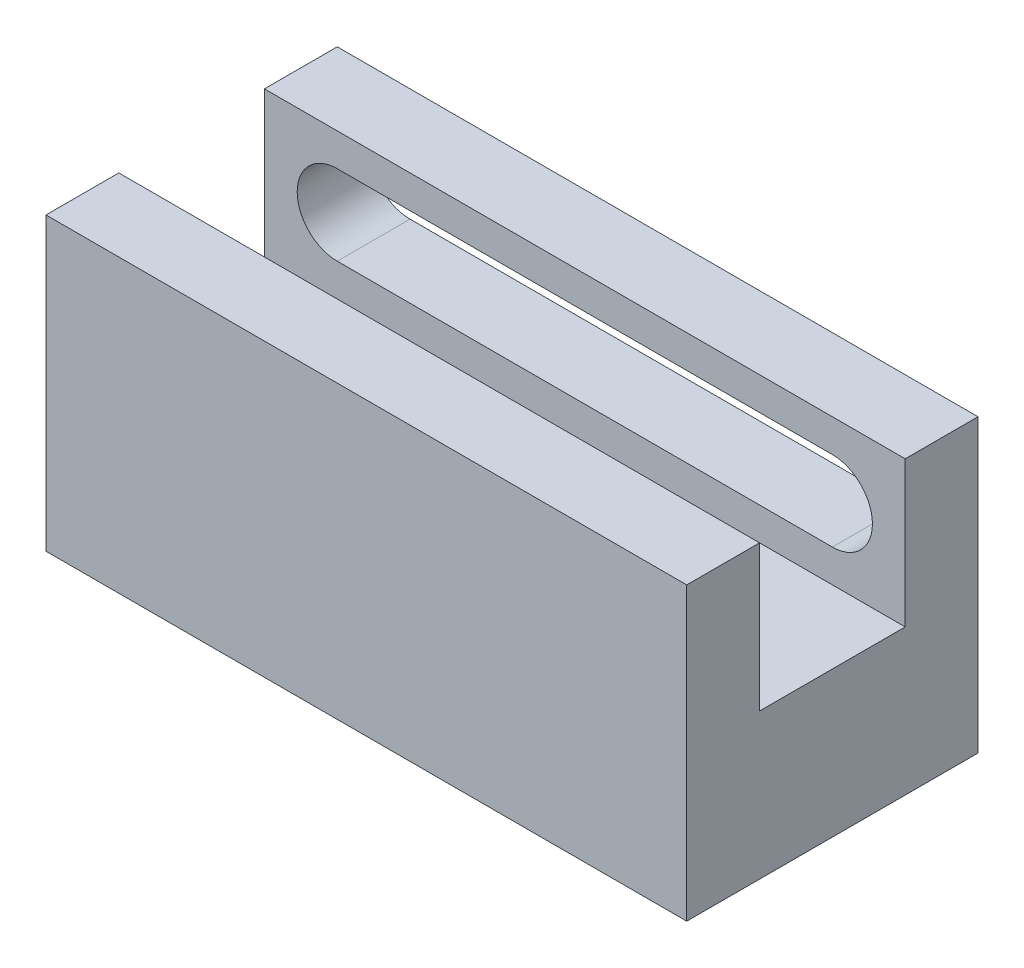
from build123d import *

# Parameters (mm, degrees)
SKETCH1_W               = 44
SKETCH1_H               = 20
SKETCH1_R               = 2.55
BOSS_EXTRUDE1_DEPTH     = 7.5
SKETCH2_W               = 44
SKETCH2_H               = 20
BOSS_EXTRUDE2_DEPTH     = 2.5
SKETCH3_W               = 44
SKETCH3_H               = 5
BOSS_EXTRUDE3_DEPTH     = 10
CUT_EXTRUDE1_DEPTH      = 1
CUT_EXTRUDE1_DEPTH_BACK = 5


with BuildPart() as part:
    # Sketch1 → Boss-Extrude1 (new body)
    with BuildSketch(Plane(origin=(0, 0, 0), x_dir=(1, 0, 0), z_dir=(0, 1, 0))):
        with Locations((22, 10)):
            Rectangle(SKETCH1_W, SKETCH1_H)
        with Locations((22, 10)):
            Circle(SKETCH1_R, mode=Mode.SUBTRACT)
    extrude(amount=BOSS_EXTRUDE1_DEPTH)

    # Sketch2 → Boss-Extrude2 (add)
    with BuildSketch(Plane(origin=(0, 7.5, 0), x_dir=(1, 0, 0), z_dir=(0, 1, 0))):
        with Locations((22, 10)):
            Rectangle(SKETCH2_W, SKETCH2_H)
    extrude(amount=BOSS_EXTRUDE2_DEPTH)

    # Sketch3 → Boss-Extrude3 (add)
    with BuildSketch(Plane(origin=(0, 10, 0), x_dir=(1, 0, 0), z_dir=(0, 1, 0))):
        with Locations((22, 2.5)):
            Rectangle(SKETCH3_W, SKETCH3_H)
        with Locations((22, 17.5)):
            Rectangle(SKETCH3_W, SKETCH3_H)
    extrude(amount=BOSS_EXTRUDE3_DEPTH)

    # Sketch4 → Cut-Extrude1 (cut, two sides)
    with BuildSketch(Plane(origin=(0, 0, -20), x_dir=(-1, 0, 0), z_dir=(0, 0, -1))) as cut_extrude1_sk:
        with BuildLine():
            Line((-5, 17.75), (-39, 17.75))
            ThreePointArc((-39, 17.75), (-37.055456352, 16.944543648), (-36.25, 15))
            ThreePointArc((-36.25, 15), (-37.055456352, 13.055456352), (-39, 12.25))
            Line((-39, 12.25), (-5, 12.25))
            ThreePointArc((-5, 12.25), (-7.75, 15), (-5, 17.75))
        make_face()
        with BuildLine():
            ThreePointArc((-36.25, 15), (-37.055456352, 16.944543648), (-39, 17.75))
            Line((-39, 17.75), (-39, 12.25))
            ThreePointArc((-39, 12.25), (-37.055456352, 13.055456352), (-36.25, 15))
        make_face()
        with BuildLine():
            Line((-39, 12.25), (-39, 17.75))
            ThreePointArc((-39, 17.75), (-41.75, 15), (-39, 12.25))
        make_face()
        with BuildLine():
            ThreePointArc((-2.25, 15), (-3.055456352, 16.944543648), (-5, 17.75))
            Line((-5, 17.75), (-5, 12.25))
            ThreePointArc((-5, 12.25), (-3.055456352, 13.055456352), (-2.25, 15))
        make_face()
        with BuildLine():
            Line((-5, 12.25), (-5, 17.75))
            ThreePointArc((-5, 17.75), (-7.75, 15), (-5, 12.25))
        make_face()
    extrude(amount=CUT_EXTRUDE1_DEPTH, mode=Mode.SUBTRACT)
    extrude(cut_extrude1_sk.sketch, amount=-CUT_EXTRUDE1_DEPTH_BACK, mode=Mode.SUBTRACT)


solid = part.part
